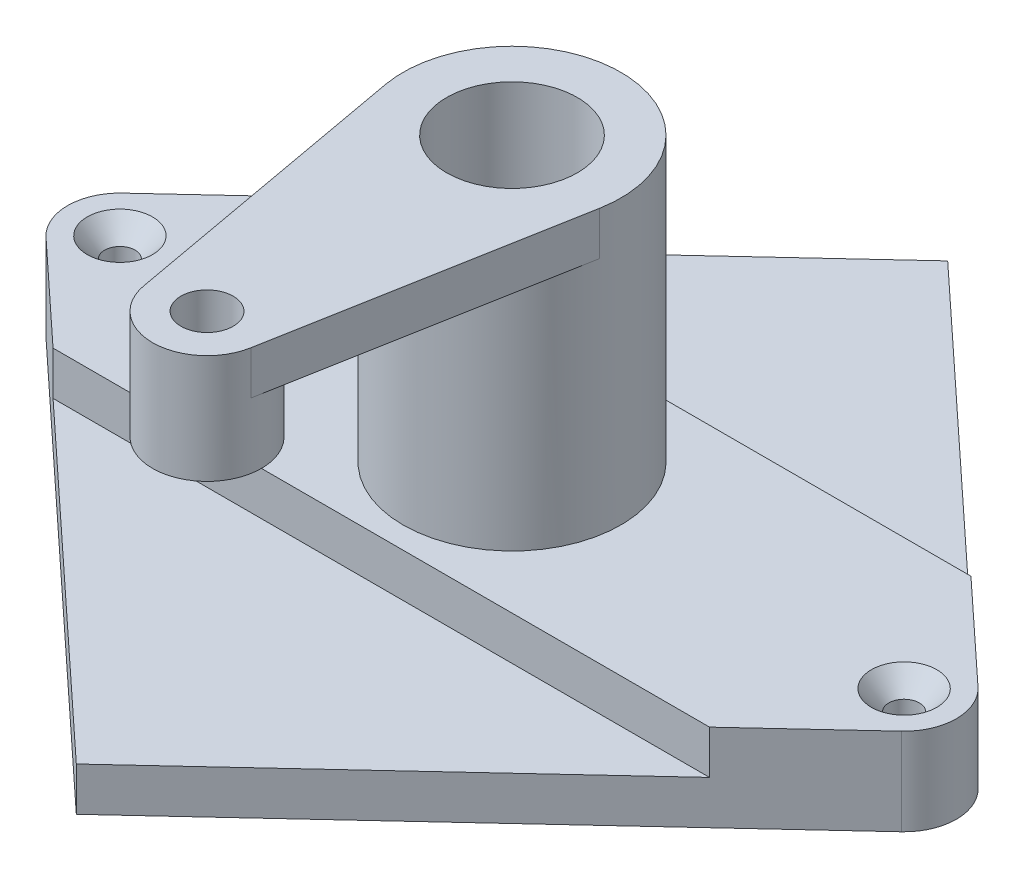
from build123d import *

# Parameters (mm, degrees)
SKETCH2_R                                           = 250
BOSS_EXTRUDE1_DEPTH                                 = 650
BOSS_EXTRUDE1_DEPTH_BACK                            = 200
SKETCH2_3_R                                         = 250
BOSS_EXTRUDE2_DEPTH                                 = 200
CUT_EXTRUDE1_DEPTH                                  = 100
BOSS_EXTRUDE4_DEPTH                                 = 100
SKETCH3_3_R                                         = 125
BOSS_EXTRUDE5_DEPTH                                 = 250
CSK_FOR_0_FLAT_HEAD_MACHINE_SCREW1_D                = 69.999999954
CSK_FOR_0_FLAT_HEAD_MACHINE_SCREW1_CSINK_D          = 149.999999974
CSK_FOR_0_FLAT_HEAD_MACHINE_SCREW1_CSINK_ANGLE      = 82
CBORE_FOR_0_BINDING_HEAD_MACHINE_SCREW1_D           = 80.00000002
CBORE_FOR_0_BINDING_HEAD_MACHINE_SCREW1_DEPTH       = 425.965575233
CBORE_FOR_0_BINDING_HEAD_MACHINE_SCREW1_CBORE_D     = 299.999999948
CBORE_FOR_0_BINDING_HEAD_MACHINE_SCREW1_CBORE_DEPTH = 350.000000024
CBORE_FOR_0_BINDING_HEAD_MACHINE_SCREW1_TIP         = 24.034424767
HOLE1_D                                             = 120
HOLE1_DEPTH                                         = 250


with BuildPart() as part:
    # Sketch2 → Boss-Extrude1 (new body, two sides)
    with BuildSketch(Plane(origin=(0, 0, 0), x_dir=(1, 0, 0), z_dir=(0, 1, 0))) as boss_extrude1_sk:
        Circle(SKETCH2_R)
    extrude(amount=BOSS_EXTRUDE1_DEPTH)
    extrude(boss_extrude1_sk.sketch, amount=-BOSS_EXTRUDE1_DEPTH_BACK)

    # Sketch2_3 → Boss-Extrude2 (add)
    with BuildSketch(Plane(origin=(0, 0, 0), x_dir=(1, 0, 0), z_dir=(0, 1, 0))):
        with BuildLine():
            Line((0, -1000), (981.679558011, -87.91160221))
            ThreePointArc((981.679558011, -87.91160221), (1020, 0), (981.679558011, 87.91160221))
            Line((981.679558011, 87.91160221), (0, 1000))
            Line((0, 1000), (-981.679558011, 87.91160221))
            ThreePointArc((-981.679558011, 87.91160221), (-1020, 0), (-981.679558011, -87.91160221))
            Line((-981.679558011, -87.91160221), (0, -1000))
        make_face()
        Circle(SKETCH2_3_R, mode=Mode.SUBTRACT)
    extrude(amount=-BOSS_EXTRUDE2_DEPTH)

    # Sketch2_5 → Cut-Extrude1 (cut)
    with BuildSketch(Plane(origin=(0, 0, 0), x_dir=(1, 0, 0), z_dir=(0, 1, 0))):
        Polygon((-753.409090909, -300), (0, -1000), (753.409090909, -300), align=None)
        Polygon((753.409090909, 300), (0, 1000), (-753.409090909, 300), align=None)
    extrude(amount=-CUT_EXTRUDE1_DEPTH, mode=Mode.SUBTRACT)

    # Sketch3 → Boss-Extrude4 (add)
    with BuildSketch(Plane(origin=(0, 650, 0), x_dir=(1, 0, 0), z_dir=(0, 1, 0))):
        with BuildLine():
            ThreePointArc((245.981737749, -44.642857143), (0, -250), (-245.981737749, -44.642857143))
            Line((-245.981737749, -44.642857143), (-122.990868875, -722.321428571))
            ThreePointArc((-122.990868875, -722.321428571), (-11.205833094, -575.503296009), (125, -700))
            ThreePointArc((125, -700), (124.496703991, -711.205833094), (122.990868875, -722.321428571))
            Line((122.990868875, -722.321428571), (245.981737749, -44.642857143))
        make_face()
    extrude(amount=-BOSS_EXTRUDE4_DEPTH)

    # Sketch3_3 → Boss-Extrude5 (add)
    with BuildSketch(Plane(origin=(0, 650, 0), x_dir=(1, 0, 0), z_dir=(0, 1, 0))):
        with Locations((0, -700)):
            Circle(SKETCH3_3_R)
    extrude(amount=-BOSS_EXTRUDE5_DEPTH)

    # CSK for _0 Flat Head Machine Screw1 (through all)
    with Locations(Plane(origin=(0, 0, 0), x_dir=(1, 0, 0), z_dir=(0, 1, 0))):
        with Locations((900, 0), (-900, 0)):
            CounterSinkHole(CSK_FOR_0_FLAT_HEAD_MACHINE_SCREW1_D / 2, CSK_FOR_0_FLAT_HEAD_MACHINE_SCREW1_CSINK_D / 2, counter_sink_angle=CSK_FOR_0_FLAT_HEAD_MACHINE_SCREW1_CSINK_ANGLE)

    # CBORE for _0 Binding Head Machine Screw1
    with Locations(Plane(origin=(0, 650, 0), x_dir=(1, 0, 0), z_dir=(0, 1, 0))):
        with Locations((0, 0)):
            CounterBoreHole(CBORE_FOR_0_BINDING_HEAD_MACHINE_SCREW1_D / 2, CBORE_FOR_0_BINDING_HEAD_MACHINE_SCREW1_CBORE_D / 2, CBORE_FOR_0_BINDING_HEAD_MACHINE_SCREW1_CBORE_DEPTH, depth=CBORE_FOR_0_BINDING_HEAD_MACHINE_SCREW1_DEPTH)
            with Locations((0, 0, -(CBORE_FOR_0_BINDING_HEAD_MACHINE_SCREW1_DEPTH + CBORE_FOR_0_BINDING_HEAD_MACHINE_SCREW1_TIP / 2))):  # 118° drill point
                Cone(0, CBORE_FOR_0_BINDING_HEAD_MACHINE_SCREW1_D / 2, CBORE_FOR_0_BINDING_HEAD_MACHINE_SCREW1_TIP, mode=Mode.SUBTRACT)

    # Hole1
    with Locations(Plane(origin=(0, 650, 0), x_dir=(1, 0, 0), z_dir=(0, 1, 0))):
        with Locations((0, -700)):
            Hole(HOLE1_D / 2, depth=HOLE1_DEPTH)


solid = part.part
